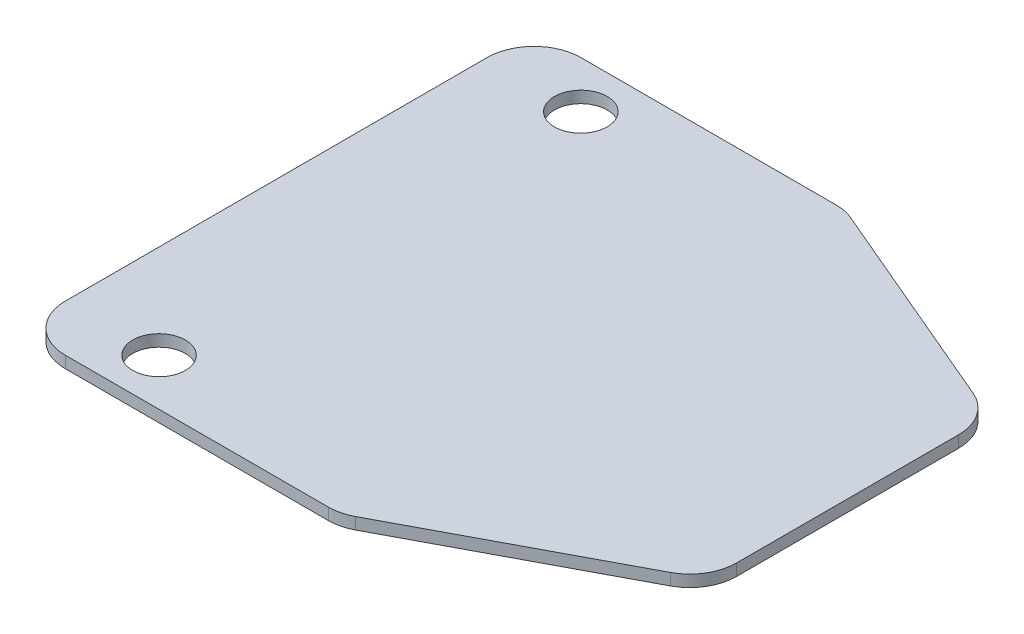
from build123d import *

# Parameters (mm, degrees)
SKETCH1_R           = 14.2875
BOSS_EXTRUDE4_DEPTH = 6.35
FILLET3_R           = 25.4


with BuildPart() as part:
    # Sketch1 → Boss-Extrude4 (new body)
    with BuildSketch(Plane(origin=(0, 0, 0), x_dir=(1, 0, 0), z_dir=(0, 1, 0))):
        Polygon((-125.816166367, -9.912218002), (4.759892389, 59.225159329), (4.759892389, 211.625159329), (-131.188630818, 269.487781998), (-300.040107611, 269.487781998), (-300.040107611, -9.912218002), align=None)
        with Locations((-249.240107611, 244.087781998)):
            Circle(SKETCH1_R, mode=Mode.SUBTRACT)
        with Locations((-249.240107611, 15.487781998)):
            Circle(SKETCH1_R, mode=Mode.SUBTRACT)
    extrude(amount=BOSS_EXTRUDE4_DEPTH)

    # Fillet3
    fillet3_edges = [part.edges().sort_by_distance(p)[0] for p in [
        (-300.040107611, 3.175, 9.912218002),
        (-300.040107611, 3.175, -269.487781998),
        (-131.188630818, 3.175, -269.487781998),
        (4.759892389, 3.175, -211.625159329),
        (4.759892389, 3.175, -59.225159329),
        (-125.816166367, 3.175, 9.912218002),
    ]]
    fillet(fillet3_edges, radius=FILLET3_R)


solid = part.part
